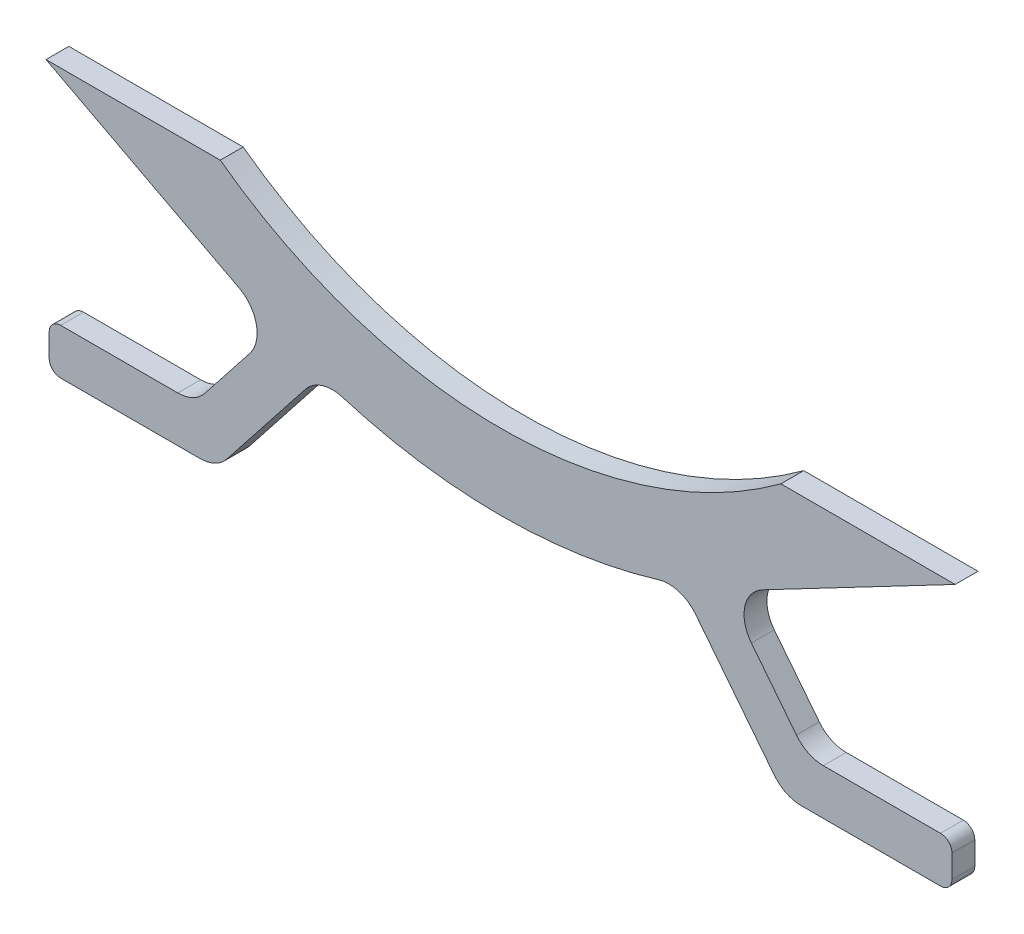
from build123d import *

# Parameters (mm, degrees)
EXTRUDE1_DEPTH       = 3.175
EXTRUDE2_DEPTH       = 6.35
EXTRUDE3_DEPTH       = 6.35
FILLET1_R            = 9.525
FILLET2_R            = 3.175
FILLET1_OF_MIRROR1_R = 9.525
FILLET2_OF_MIRROR1_R = 3.175


with BuildPart() as part:
    # Sketch1 → Extrude1 (new body, symmetric)
    with BuildSketch(Plane.XY):
        with BuildLine():
            Line((218.47175, -3.175), (186.72175, -3.175))
            ThreePointArc((186.72175, -3.175), (108.839, -28.738144468), (30.95625, -3.175))
            Line((30.95625, -3.175), (-0.79375, -3.175))
            ThreePointArc((-0.79375, -3.175), (108.839, -49.714619652), (218.47175, -3.175))
        make_face()
    extrude(amount=EXTRUDE1_DEPTH, both=True)

    # Sketch2 → Extrude2 (add)
    with BuildSketch(Plane(origin=(0, 0, -3.175), x_dir=(-1, 0, 0), z_dir=(0, 0, -1))):
        with BuildLine():
            Line((16.5735, -77.7875), (-29.946040711, -77.7875))
            Line((-29.946040711, -77.7875), (-58.727389514, -41.240247997))
            ThreePointArc((-58.727389514, -41.240247997), (-52.51922119, -38.926209978), (-46.417495888, -36.344529471))
            Line((-46.417495888, -36.344529471), (-23.782101567, -65.0875))
            Line((-23.782101567, -65.0875), (16.5735, -65.0875))
            Line((16.5735, -65.0875), (16.5735, -77.7875))
        make_face()
    extrude2 = extrude(amount=-EXTRUDE2_DEPTH)

    # Sketch3 → Extrude3 (add)
    with BuildSketch(Plane.XY.offset(3.175)):
        with BuildLine():
            Line((179.598329003, -32.291941299), (235.1405, -3.175))
            Line((235.1405, -3.175), (218.47175, -3.175))
            ThreePointArc((218.47175, -3.175), (200.202420522, -19.2920167), (179.598329003, -32.291941299))
        make_face()
    extrude3 = extrude(amount=-EXTRUDE3_DEPTH)

    # Fillet1
    fillet1_edges = [part.edges().sort_by_distance(p)[0] for p in [
        (29.946040711, -77.7875, 0),
        (58.727389514, -41.240247997, 0),
        (46.417495888, -36.344529471, 0),
        (23.782101567, -65.0875, 0),
    ]]
    fillet(fillet1_edges, radius=FILLET1_R)

    # Fillet2
    fillet2_edges = [part.edges().sort_by_distance(p)[0] for p in [
        (-16.5735, -65.0875, 0),
        (-16.5735, -77.7875, 0),
    ]]
    fillet(fillet2_edges, radius=FILLET2_R)

    # Mirror1: Extrude2, Extrude3 across plane
    add(extrude2.mirror(Plane(origin=(108.839, 0, 0), x_dir=(0, 0, 1), z_dir=(1, 0, 0))))
    add(extrude3.mirror(Plane(origin=(108.839, 0, 0), x_dir=(0, 0, 1), z_dir=(1, 0, 0))))

    # Fillet1 of Mirror1
    fillet1_of_mirror1_edges = [part.edges().sort_by_distance(p)[0] for p in [
        (187.731959289, -77.7875, 0),
        (158.950610486, -41.240247997, 0),
        (171.260504112, -36.344529471, 0),
        (193.895898433, -65.0875, 0),
    ]]
    fillet(fillet1_of_mirror1_edges, radius=FILLET1_OF_MIRROR1_R)

    # Fillet2 of Mirror1
    fillet2_of_mirror1_edges = [part.edges().sort_by_distance(p)[0] for p in [
        (234.2515, -65.0875, 0),
        (234.2515, -77.7875, 0),
    ]]
    fillet(fillet2_of_mirror1_edges, radius=FILLET2_OF_MIRROR1_R)


solid = part.part
